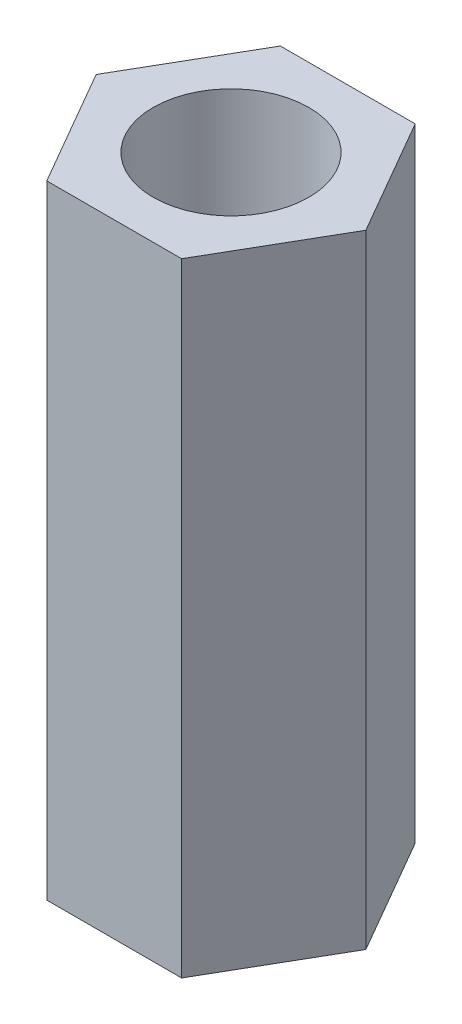
from build123d import *

# Parameters (mm, degrees)
BOSS_EXTRUDE1_DEPTH = 12
SKETCH3_R           = 1.5
CUT_EXTRUDE1_DEPTH  = 13


with BuildPart() as part:
    # Sketch2 → Boss-Extrude1 (new body)
    with BuildSketch(Plane(origin=(0, 0, 0), x_dir=(1, 0, 0), z_dir=(0, 1, 0))):
        Polygon((-1.299038106, 2.25), (-2.598076211, 0), (-1.299038106, -2.25), (1.299038106, -2.25), (2.598076211, 0), (1.299038106, 2.25), align=None)
    extrude(amount=BOSS_EXTRUDE1_DEPTH)

    # Sketch3 → Cut-Extrude1 (cut, through all)
    with BuildSketch(Plane(origin=(0, 12, 0), x_dir=(1, 0, 0), z_dir=(0, 1, 0))):
        Circle(SKETCH3_R)
    extrude(amount=-CUT_EXTRUDE1_DEPTH, mode=Mode.SUBTRACT)


solid = part.part
